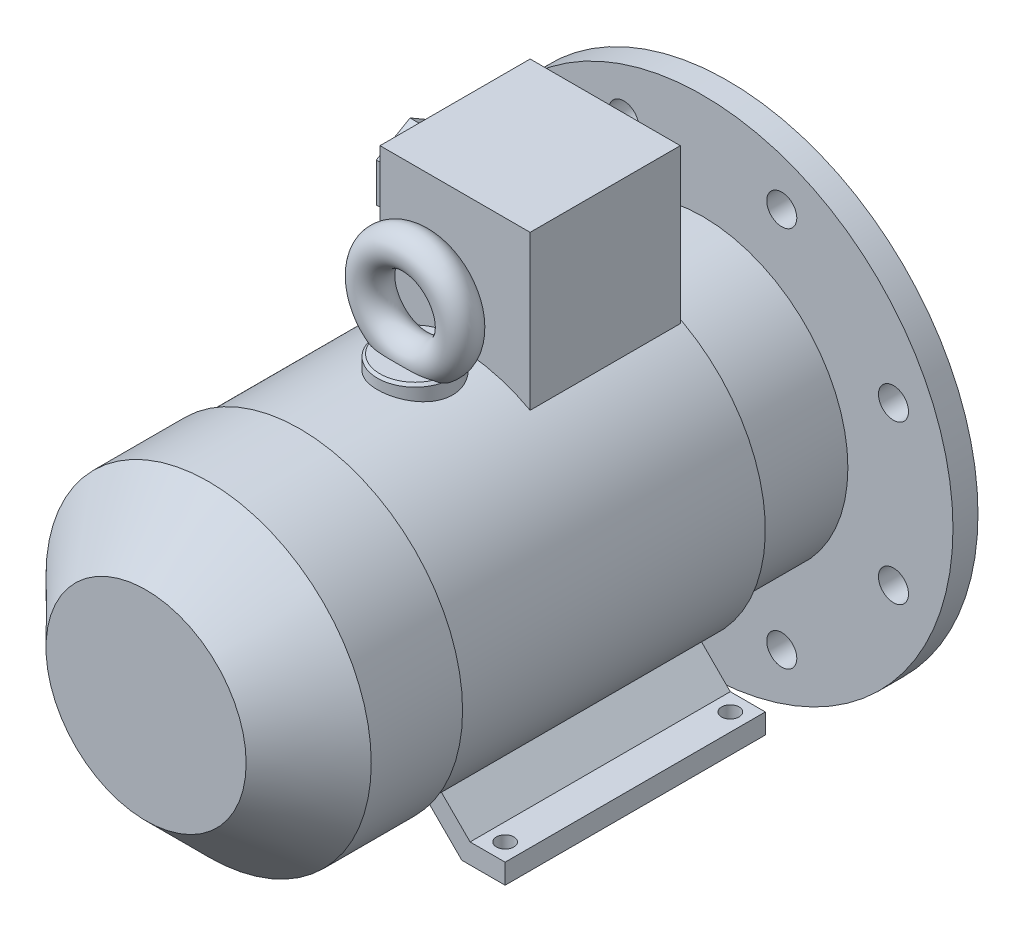
from build123d import *

# Parameters (mm, degrees)
SKETCH_2_R           = 9.5
EXTRUDE_1_DEPTH      = 40
SKETCH_3_W           = 6
SKETCH_3_H           = 6
EXTRUDE_2_DEPTH      = 0.1
EXTRUDE_2_DEPTH_BACK = 25
CHAMFER_1_SIZE       = 1
SKETCH_4_R           = 100
EXTRUDE_3_DEPTH      = 10
SKETCH_5_R           = 60
SKETCH_5_R_2         = 15
CUT_EXTRUDE_1_DEPTH  = 4
SKETCH_7_R           = 65
SKETCH_7_R_2         = 60
EXTRUDE_4_DEPTH      = 3.5
CHAMFER_2_SIZE       = 1
SKETCH_8_R           = 6
CUT_EXTRUDE_2_DEPTH  = 11
CHAMFER_3_SIZE       = 1
SKETCH_9_R           = 58
EXTRUDE_5_DEPTH      = 38
SKETCH_10_R          = 63
EXTRUDE_6_DEPTH      = 123
SKETCH_11_R          = 65
EXTRUDE_7_DEPTH      = 61.5
CHAMFER_4_SIZE       = 25
EXTRUDE_8_DEPTH      = 104
CUT_EXTRUDE_3_REACH  = 173
SKETCH_13_R          = 3.5
SKETCH_14_W          = 60
SKETCH_14_H          = 60
EXTRUDE_9_DEPTH      = 117
SKETCH_15_R          = 15
EXTRUDE_10_DEPTH     = 68
CHAMFER_5_SIZE       = 1
SKETCH_17_R          = 7
SKETCH_18_R          = 9
EXTRUDE_11_DEPTH     = 8
EXTRUDE_12_DEPTH     = 10
SKETCH_20_R          = 6
CUT_EXTRUDE_4_DEPTH  = 10


with BuildPart() as part:
    # Эскиз2 → Вытянуть1 (new body)
    with BuildSketch(Plane.XY):
        Circle(SKETCH_2_R)
    extrude(amount=EXTRUDE_1_DEPTH)

    # Эскиз3 → Вытянуть2 (add, two sides)
    with BuildSketch(Plane(origin=(0, 0, 0), x_dir=(-1, 0, 0), z_dir=(0, 0, -1))) as extrude_2_sk:
        with Locations((0, 9)):
            Rectangle(SKETCH_3_W, SKETCH_3_H)
    extrude(amount=EXTRUDE_2_DEPTH)
    extrude(extrude_2_sk.sketch, amount=-EXTRUDE_2_DEPTH_BACK)

    # Фаска1
    chamfer_1_edges = [part.edges().sort_by_distance(p)[0] for p in [
        (-5.556527693, -7.705517504, 0),
    ]]
    chamfer(chamfer_1_edges, length=CHAMFER_1_SIZE)

    # Эскиз4 → Вытянуть3 (add)
    with BuildSketch(Plane.XY.offset(40)):
        Circle(SKETCH_4_R)
    extrude(amount=EXTRUDE_3_DEPTH)

    # Эскиз5 → Вырез-Вытянуть1 (cut)
    with BuildSketch(Plane(origin=(0, 0, 40), x_dir=(-1, 0, 0), z_dir=(0, 0, -1))):
        Circle(SKETCH_5_R)
        Circle(SKETCH_5_R_2, mode=Mode.SUBTRACT)
    extrude(amount=-CUT_EXTRUDE_1_DEPTH, mode=Mode.SUBTRACT)

    # Эскиз7 → Вытянуть4 (add)
    with BuildSketch(Plane(origin=(0, 0, 40), x_dir=(-1, 0, 0), z_dir=(0, 0, -1))):
        with Locations(Location((0, 0, 0), (0, 0, 180))):  # turned: the seam where the file's is
            Circle(SKETCH_7_R)
        Circle(SKETCH_7_R_2, mode=Mode.SUBTRACT)
    extrude(amount=EXTRUDE_4_DEPTH)

    # Фаска2
    chamfer_2_edges = [part.edges().sort_by_distance(p)[0] for p in [
        (-65, 0, 36.5),
    ]]
    chamfer(chamfer_2_edges, length=CHAMFER_2_SIZE)

    # Эскиз8 → Вырез-Вытянуть2 (cut, through all)
    with BuildSketch(Plane(origin=(0, 0, 40), x_dir=(-1, 0, 0), z_dir=(0, 0, -1))):
        with Locations((-31.57138317, 76.220061432)):
            Circle(SKETCH_8_R)
        with Locations((31.57138317, 76.220061432)):
            Circle(SKETCH_8_R)
        with Locations((76.220061432, 31.57138317)):
            Circle(SKETCH_8_R)
        with Locations((76.220061432, -31.57138317)):
            Circle(SKETCH_8_R)
        with Locations((31.57138317, -76.220061432)):
            Circle(SKETCH_8_R)
        with Locations((-31.57138317, -76.220061432)):
            Circle(SKETCH_8_R)
        with Locations((-76.220061432, -31.57138317)):
            Circle(SKETCH_8_R)
        with Locations((-76.220061432, 31.57138317)):
            Circle(SKETCH_8_R)
    extrude(amount=-CUT_EXTRUDE_2_DEPTH, mode=Mode.SUBTRACT)

    # Фаска3
    chamfer_3_edges = [part.edges().sort_by_distance(p)[0] for p in [
        (15, 0, 40),
    ]]
    chamfer(chamfer_3_edges, length=CHAMFER_3_SIZE)

    # Эскиз9 → Вытянуть5 (add)
    with BuildSketch(Plane.XY.offset(50)):
        Circle(SKETCH_9_R)
    extrude(amount=EXTRUDE_5_DEPTH)

    # Эскиз10 → Вытянуть6 (add)
    with BuildSketch(Plane.XY.offset(88)):
        Circle(SKETCH_10_R)
    extrude(amount=EXTRUDE_6_DEPTH)

    # Эскиз11 → Вытянуть7 (add)
    with BuildSketch(Plane.XY.offset(211)):
        Circle(SKETCH_11_R)
    extrude(amount=EXTRUDE_7_DEPTH)

    # Фаска4
    chamfer_4_edges = [part.edges().sort_by_distance(p)[0] for p in [
        (-65, 0, 272.5),
    ]]
    chamfer(chamfer_4_edges, length=CHAMFER_4_SIZE)

    # Эскиз12 → Вытянуть8 (add)
    with BuildSketch(Plane(origin=(0, 0, 88), x_dir=(-1, 0, 0), z_dir=(0, 0, -1))):
        Polygon((-45.686291501, -71), (-63, -71), (-63, -63), (-49, -63), (-34.844951906, -48.844951906), (-27.837639703, -53.151348202), align=None)
        Polygon((45.686291501, -71), (63, -71), (63, -63), (49, -63), (34.844951906, -48.844951906), (27.837639703, -53.151348202), align=None)
    extrude(amount=-EXTRUDE_8_DEPTH)

    # Эскиз13 → Вырез-Вытянуть3 (cut, up to next)
    with BuildSketch(Plane.XZ.offset(71), mode=Mode.PRIVATE) as cut_extrude_3_sk1:
        with Locations(Location((-56, 95, 0), (0, 0, 270))):  # turned: the seam where the file's is
            Circle(SKETCH_13_R)
    cut_extrude_3_tool1 = extrude(cut_extrude_3_sk1.sketch, amount=-CUT_EXTRUDE_3_REACH, mode=Mode.PRIVATE) & part.part
    add(cut_extrude_3_tool1.solids().sort_by_distance((-56, -71, 95))[0], mode=Mode.SUBTRACT)
    # Эскиз13 → Вырез-Вытянуть3 (cut, up to next)
    with BuildSketch(Plane.XZ.offset(71), mode=Mode.PRIVATE) as cut_extrude_3_sk2:
        with Locations(Location((56, 95, 0), (0, 0, 270))):  # turned: the seam where the file's is
            Circle(SKETCH_13_R)
    cut_extrude_3_tool2 = extrude(cut_extrude_3_sk2.sketch, amount=-CUT_EXTRUDE_3_REACH, mode=Mode.PRIVATE) & part.part
    add(cut_extrude_3_tool2.solids().sort_by_distance((56, -71, 95))[0], mode=Mode.SUBTRACT)
    # Эскиз13 → Вырез-Вытянуть3 (cut, up to next)
    with BuildSketch(Plane.XZ.offset(71), mode=Mode.PRIVATE) as cut_extrude_3_sk3:
        with Locations(Location((-56, 185, 0), (0, 0, 270))):  # turned: the seam where the file's is
            Circle(SKETCH_13_R)
    cut_extrude_3_tool3 = extrude(cut_extrude_3_sk3.sketch, amount=-CUT_EXTRUDE_3_REACH, mode=Mode.PRIVATE) & part.part
    add(cut_extrude_3_tool3.solids().sort_by_distance((-56, -71, 185))[0], mode=Mode.SUBTRACT)
    # Эскиз13 → Вырез-Вытянуть3 (cut, up to next)
    with BuildSketch(Plane.XZ.offset(71), mode=Mode.PRIVATE) as cut_extrude_3_sk4:
        with Locations(Location((56, 185, 0), (0, 0, 270))):  # turned: the seam where the file's is
            Circle(SKETCH_13_R)
    cut_extrude_3_tool4 = extrude(cut_extrude_3_sk4.sketch, amount=-CUT_EXTRUDE_3_REACH, mode=Mode.PRIVATE) & part.part
    add(cut_extrude_3_tool4.solids().sort_by_distance((56, -71, 185))[0], mode=Mode.SUBTRACT)

    # Эскиз14 → Вытянуть9 (add)
    with BuildSketch(Plane(origin=(0, 0, 0), x_dir=(1, 0, 0), z_dir=(0, 1, 0))):
        with Locations((0, -119)):
            Rectangle(SKETCH_14_W, SKETCH_14_H)
    extrude(amount=EXTRUDE_9_DEPTH)

    # Эскиз15 → Вытянуть10 (add)
    with BuildSketch(Plane(origin=(0, 0, 0), x_dir=(1, 0, 0), z_dir=(0, 1, 0))):
        with Locations(Location((0, -165, 0), (0, 0, 90))):  # turned: the seam where the file's is
            Circle(SKETCH_15_R)
    extrude(amount=EXTRUDE_10_DEPTH)

    # Фаска5
    chamfer_5_edges = [part.edges().sort_by_distance(p)[0] for p in [
        (0, 68, 180),
    ]]
    chamfer(chamfer_5_edges, length=CHAMFER_5_SIZE)

    # По траектории1: sweep along a path in Эскиз16
    with BuildLine(Plane.XY.offset(165)) as sweep_1_path:
        CenterArc((0, 86), 18, 0, 360)
    # Эскиз17 → По траектории1 (sweep)
    with BuildSketch(Plane(origin=(0, 0, 0), x_dir=(0, 0, -1), z_dir=(1, 0, 0))):
        with Locations((-165, 104)):
            Circle(SKETCH_17_R)
    sweep(path=sweep_1_path.line)

    # Эскиз18 → Вытянуть11 (add)
    with BuildSketch(Plane.ZY.offset(30)):
        with Locations(Location((119, 87, 0), (0, 0, 180))):  # turned: the seam where the file's is
            Circle(SKETCH_18_R)
    extrude(amount=EXTRUDE_11_DEPTH)

    # Эскиз19 → Вытянуть12 (add)
    with BuildSketch(Plane.ZY.offset(38)):
        Polygon((119, 102.588457268), (105.5, 94.794228634), (105.5, 79.205771366), (119, 71.411542732), (132.5, 79.205771366), (132.5, 94.794228634), align=None)
    extrude(amount=EXTRUDE_12_DEPTH)

    # Эскиз20 → Вырез-Вытянуть4 (cut)
    with BuildSketch(Plane.ZY.offset(48)):
        with Locations((119, 87)):
            Circle(SKETCH_20_R)
    extrude(amount=-CUT_EXTRUDE_4_DEPTH, mode=Mode.SUBTRACT)


solid = part.part
